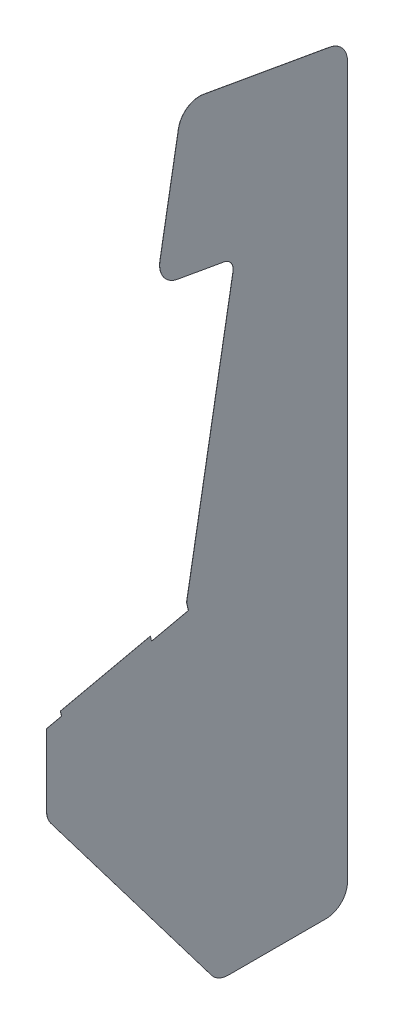
from build123d import *

# Parameters (mm, degrees)
BOSS_EXTRUDE1_DEPTH = 0.1016
FILLET1_R           = 25.4
BOSS_EXTRUDE2_DEPTH = 0.2032
FILLET2_R           = 6.35
BOSS_EXTRUDE3_DEPTH = 0.2032


with BuildPart() as part:
    # Sketch1 → Boss-Extrude1 (new body, symmetric)
    with BuildSketch(Plane(origin=(0, 0, 0), x_dir=(0, 0, -1), z_dir=(1, 0, 0))):
        Polygon((0, 0), (0, -112.563749307), (261.582885953, -457.593888215), (450.85, -457.593888215), (450.85, 690.679166755), (208.861297127, 733.352902663), (171.366736958, 520.733599781), (293.482501466, 499.198975136), (217.390599948, 67.706860465), (221.513774593, 49.108421529), align=None)
    extrude(amount=BOSS_EXTRUDE1_DEPTH, both=True)

    # Fillet1
    fillet1_edges = [part.edges().sort_by_distance(p)[0] for p in [
        (0, 499.198975136, -293.482501466),
        (0, 520.733599781, -171.366736958),
        (0, 733.352902663, -208.861297127),
        (0, 690.679166755, -450.85),
        (0, -457.593888215, -450.85),
        (0, -457.593888215, -261.582885953),
        (0, -112.563749307, 0),
    ]]
    fillet(fillet1_edges, radius=FILLET1_R)

    # Sketch5 → Boss-Extrude2 (add)
    with BuildSketch(Plane(origin=(0.1016, 0, 0), x_dir=(0, 0, -1), z_dir=(1, 0, 0))):
        Polygon((24.797918581, 5.497566194), (23.079929145, 13.246915751), (147.069522049, 40.734746721), (148.787511485, 32.985397164), align=None)
    extrude(amount=-BOSS_EXTRUDE2_DEPTH)

    # Fillet2
    fillet2_edges = [part.edges().sort_by_distance(p)[0] for p in [
        (0, 32.985397164, -148.787511485),
        (0, 5.497566194, -24.797918581),
    ]]
    fillet(fillet2_edges, radius=FILLET2_R)

    # Sketch7 → Boss-Extrude3 (add)
    with BuildSketch(Plane(origin=(0.1016, 0, 0), x_dir=(0, 0, -1), z_dir=(1, 0, 0))):
        with BuildLine():
            Line((274.200562117, -465.531388215), (425.45, -465.531388215))
            ThreePointArc((425.45, -465.531388215), (449.023172318, -455.767060533), (458.7875, -432.193888215))
            Line((458.7875, -432.193888215), (458.7875, 669.366434984))
            ThreePointArc((458.7875, 669.366434984), (450.988204091, 690.795131586), (431.239601202, 702.197356752))
            Line((431.239601202, 702.197356752), (235.253809237, 736.758664072))
            ThreePointArc((235.253809237, 736.758664072), (210.34310689, 731.236575989), (196.633286266, 709.717343506))
            Line((196.633286266, 709.717343506), (167.960975549, 547.126111891))
            ThreePointArc((167.960975549, 547.126111891), (173.483063631, 522.215409544), (195.002296115, 508.50558892))
            Line((195.002296115, 508.50558892), (267.089989356, 495.793213726))
            ThreePointArc((267.089989356, 495.793213726), (278.361968276, 488.611879114), (281.254490605, 475.56341598))
            Line((281.254490605, 475.56341598), (209.299504588, 67.530386732))
            Line((209.299504588, 67.530386732), (212.046435601, 55.13978165))
            Line((212.046435601, 55.13978165), (154.818871606, 42.452736156))
            Line((154.818871606, 42.452736156), (153.10088217, 50.202085713))
            Line((153.10088217, 50.202085713), (13.612590153, 19.278275871))
            Line((13.612590153, 19.278275871), (15.330579589, 11.528926315))
            Line((15.330579589, 11.528926315), (-7.9375, 6.37051726))
            Line((-7.9375, 6.37051726), (-7.9375, -104.02374744))
            ThreePointArc((-7.9375, -104.02374744), (-6.199252731, -114.648065445), (-1.165778481, -124.164460435))
            Line((-1.165778481, -124.164460435), (247.634783637, -452.33460121))
            ThreePointArc((247.634783637, -452.33460121), (259.369043538, -462.050461408), (274.200562117, -465.531388215))
        make_face()
    extrude(amount=-BOSS_EXTRUDE3_DEPTH)


solid = part.part
